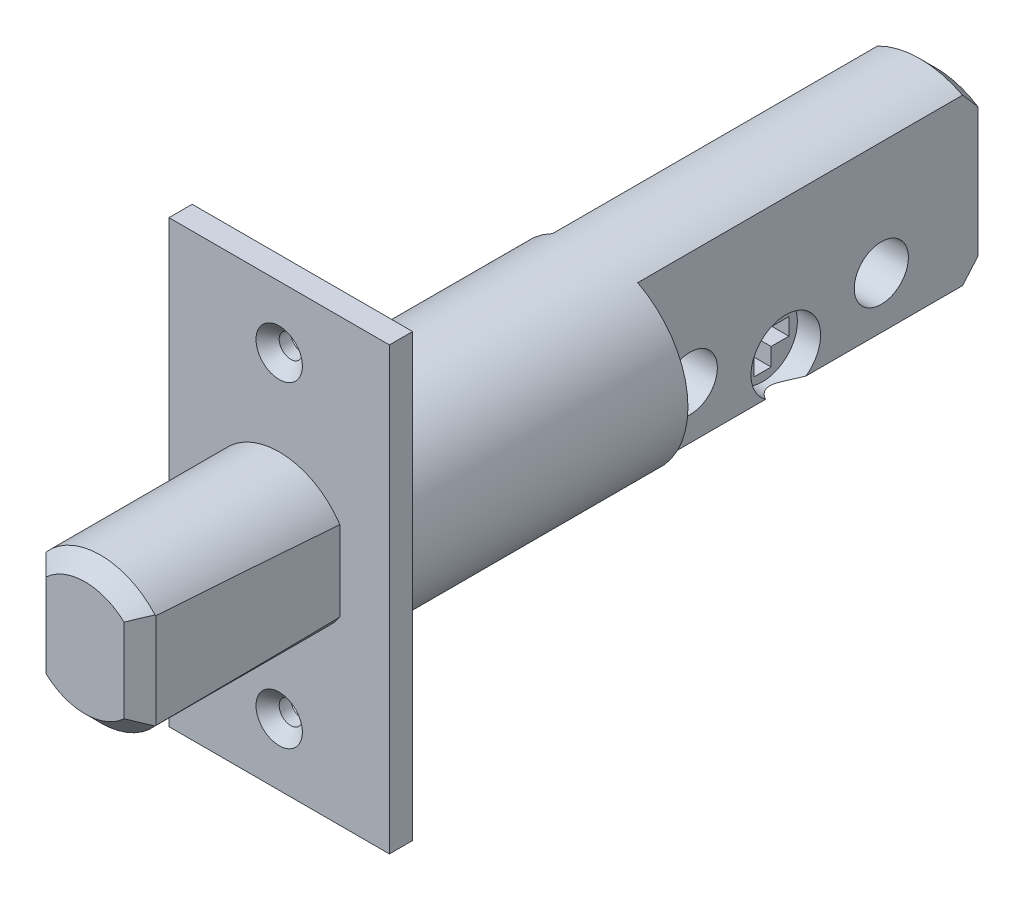
from build123d import *
from OCP.BRepFilletAPI import BRepFilletAPI_MakeChamfer

# Parameters (mm, degrees)
SKETCH2_R                = 12
BOSS_EXTRUDE1_DEPTH      = 81.85
SKETCH3_W                = 28.5
SKETCH3_H                = 57
SKETCH3_R                = 1.5
BOSS_EXTRUDE2_DEPTH      = 3
CHAMFER1_SIZE            = 1.5
SKETCH4_R                = 9.4
BOSS_EXTRUDE3_DEPTH      = 25.1
CUT_EXTRUDE1_DEPTH       = 88.8335642
CUT_EXTRUDE1_DEPTH_BACK  = 88.8335642
CHAMFER2_SIZE            = 2
CHAMFER2_SIZE2           = 2.066892656
CHAMFER3_SIZE            = 2
SKETCH6_R                = 4.5
CUT_EXTRUDE2_DEPTH       = 88.8335642
CUT_EXTRUDE2_DEPTH_BACK  = 88.8335642
SKETCH7_W                = 35.652875986
SKETCH7_H                = 43.298184849
SKETCH7_W_2              = 11
SKETCH7_H_2              = 30
CUT_EXTRUDE3_DEPTH       = 44
SKETCH8_R                = 4.5
BOSS_EXTRUDE4_DEPTH      = 2.5
BOSS_EXTRUDE4_DEPTH_BACK = 2.5
SKETCH9_R                = 3.5
CUT_EXTRUDE4_DEPTH       = 89.891703775


with BuildPart() as part:
    # Sketch2 → Boss-Extrude1 (new body)
    with BuildSketch(Plane.XY):
        Circle(SKETCH2_R)
    extrude(amount=-BOSS_EXTRUDE1_DEPTH)

    # Sketch3 → Boss-Extrude2 (add)
    with BuildSketch(Plane.XY):
        Rectangle(SKETCH3_W, SKETCH3_H)
        with Locations((0, 20.5)):
            Circle(SKETCH3_R, mode=Mode.SUBTRACT)
        with Locations((0, -20.5)):
            Circle(SKETCH3_R, mode=Mode.SUBTRACT)
    extrude(amount=BOSS_EXTRUDE2_DEPTH)

    # Chamfer1
    chamfer1_edges = [part.edges().sort_by_distance(p)[0] for p in [
        (-1.5, 20.5, 3),
        (-1.5, -20.5, 3),
    ]]
    chamfer(chamfer1_edges, length=CHAMFER1_SIZE)

    # Sketch4 → Boss-Extrude3 (add)
    with BuildSketch(Plane.XY.offset(3)):
        Circle(SKETCH4_R)
    extrude(amount=BOSS_EXTRUDE3_DEPTH)

    # Sketch5 → Cut-Extrude1 (cut, two sides)
    with BuildSketch(Plane(origin=(0, 0, 0), x_dir=(1, 0, 0), z_dir=(0, 1, 0))) as cut_extrude1_sk:
        Polygon((-7.85, -3), (-7.05, -28.1), (-9.4, -28.1), (-9.4, -3), align=None)
        Polygon((9.4, -3), (7.85, -3), (7.05, -28.1), (9.4, -28.1), align=None)
    extrude(amount=CUT_EXTRUDE1_DEPTH, mode=Mode.SUBTRACT)
    extrude(cut_extrude1_sk.sketch, amount=-CUT_EXTRUDE1_DEPTH_BACK, mode=Mode.SUBTRACT)

    # Chamfer2: one chamfer whose edges measure the first distance from different faces: ONE call of the kernel's chamfer builder (chamfer() names one face for all edges)
    chamfer2_edges_1 = [part.edges().sort_by_distance(p)[0] for p in [
        (0, -9.4, 28.1),
        (0, 9.4, 28.1),
    ]]
    chamfer2_edges_2 = [part.edges().sort_by_distance(p)[0] for p in [
        (7.05, 0, 28.1),
        (-7.05, 0, 28.1),
    ]]
    chamfer2_side_2 = [part.faces().sort_by_distance(p)[0] for p in [
        (0, 0, 28.1),
    ]]
    chamfer2 = BRepFilletAPI_MakeChamfer(part.part.solid().wrapped)
    for e in chamfer2_edges_1:
        chamfer2.Add(CHAMFER2_SIZE, e.wrapped)
    for e in chamfer2_edges_2:
        chamfer2.Add(CHAMFER2_SIZE, CHAMFER2_SIZE2, e.wrapped, chamfer2_side_2[0].wrapped)  # the first distance lies on this face
    add(Compound.cast(chamfer2.Shape()), mode=Mode.REPLACE)

    # Chamfer3
    chamfer3_edges = [part.edges().sort_by_distance(p)[0] for p in [
        (-12, 0, -81.85),
    ]]
    chamfer(chamfer3_edges, length=CHAMFER3_SIZE)

    # Sketch6 → Cut-Extrude2 (cut, two sides)
    with BuildSketch(Plane(origin=(0, 0, 0), x_dir=(0, 0, -1), z_dir=(1, 0, 0))) as cut_extrude2_sk:
        with Locations((57, -7)):
            Circle(SKETCH6_R)
    extrude(amount=CUT_EXTRUDE2_DEPTH, mode=Mode.SUBTRACT)
    extrude(cut_extrude2_sk.sketch, amount=-CUT_EXTRUDE2_DEPTH_BACK, mode=Mode.SUBTRACT)

    # Sketch7 → Cut-Extrude3 (cut)
    with BuildSketch(Plane(origin=(0, 0, -81.85), x_dir=(-1, 0, 0), z_dir=(0, 0, -1))):
        with Locations((0.794809337, 0.340632573)):
            Rectangle(SKETCH7_W, SKETCH7_H)
        Rectangle(SKETCH7_W_2, SKETCH7_H_2, mode=Mode.SUBTRACT)
    extrude(amount=-CUT_EXTRUDE3_DEPTH, mode=Mode.SUBTRACT)

    # Sketch8 → Boss-Extrude4 (add, two sides)
    with BuildSketch(Plane(origin=(0, 0, 0), x_dir=(0, 0, -1), z_dir=(1, 0, 0))) as boss_extrude4_sk:
        with Locations((57, -7)):
            Circle(SKETCH8_R)
        Polygon((55.9, -5.9), (55.9, -3.6), (58.1, -3.6), (58.1, -5.9), (60.4, -5.9), (60.4, -8.1), (58.1, -8.1), (58.1, -10.4), (55.9, -10.4), (55.9, -8.1), (53.6, -8.1), (53.6, -5.9), align=None, mode=Mode.SUBTRACT)
    extrude(amount=BOSS_EXTRUDE4_DEPTH)
    extrude(boss_extrude4_sk.sketch, amount=-BOSS_EXTRUDE4_DEPTH_BACK)

    # Sketch9 → Cut-Extrude4 (cut, through all)
    with BuildSketch(Plane(origin=(5.5, 0, 0), x_dir=(0, 0, -1), z_dir=(1, 0, 0))):
        with Locations(Location((44.65, -4, 0), (0, 0, 90))):
            Circle(SKETCH9_R)
        with Locations(Location((69.35, -4, 0), (0, 0, 90))):
            Circle(SKETCH9_R)
    extrude(amount=-CUT_EXTRUDE4_DEPTH, mode=Mode.SUBTRACT)


solid = part.part
